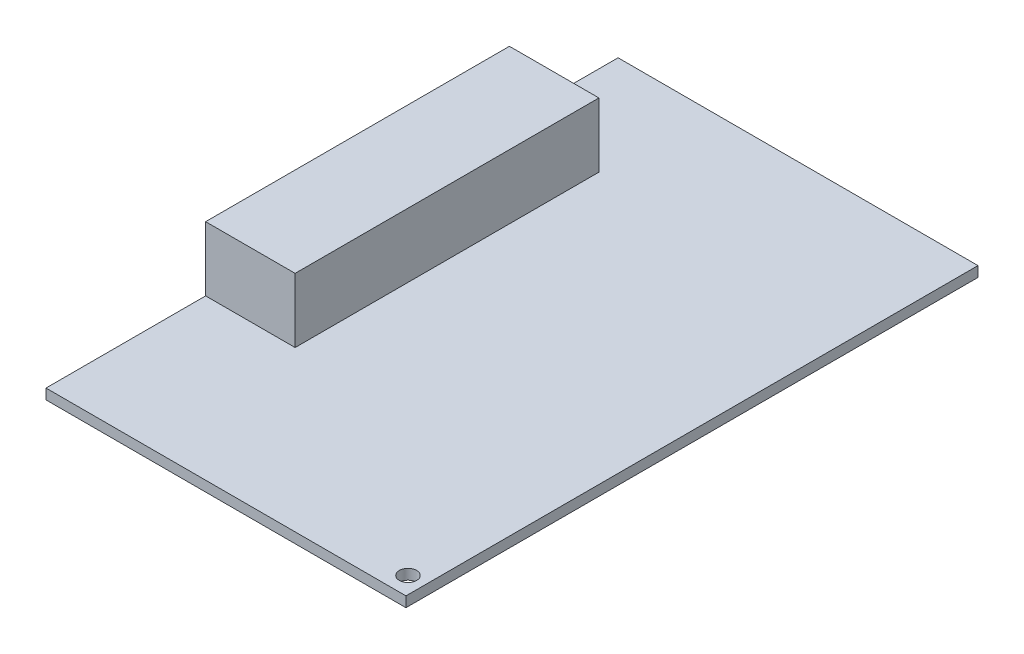
from build123d import *

# Parameters (mm, degrees)
SKETCH_1_W          = 56
SKETCH_1_H          = 89
EXTRUDE_1_DEPTH     = 1.6
SKETCH_2_W          = 13.9249856
SKETCH_2_H          = 47.2640512
EXTRUDE_2_DEPTH     = 10
SKETCH_3_R          = 1.35
CUT_EXTRUDE_1_DEPTH = 10


with BuildPart() as part:
    # 草图1 → 凸台-拉伸1 (new body)
    with BuildSketch(Plane(origin=(0, 0, 0), x_dir=(1, 0, 0), z_dir=(0, 1, 0))):
        Rectangle(SKETCH_1_W, SKETCH_1_H)
    extrude(amount=EXTRUDE_1_DEPTH)

    # 草图2 → 凸台-拉伸2 (add)
    with BuildSketch(Plane(origin=(0, 1.6, 0), x_dir=(1, 0, 0), z_dir=(0, 1, 0))):
        with Locations((-21.0375072, 3.96574336)):
            Rectangle(SKETCH_2_W, SKETCH_2_H)
    extrude(amount=EXTRUDE_2_DEPTH)

    # 草图3 → 切除-拉伸1 (cut)
    with BuildSketch(Plane(origin=(0, 1.6, 0), x_dir=(1, 0, 0), z_dir=(0, 1, 0))):
        with Locations((25.41, -41.59)):
            Circle(SKETCH_3_R)
    extrude(amount=-CUT_EXTRUDE_1_DEPTH, mode=Mode.SUBTRACT)


solid = part.part
